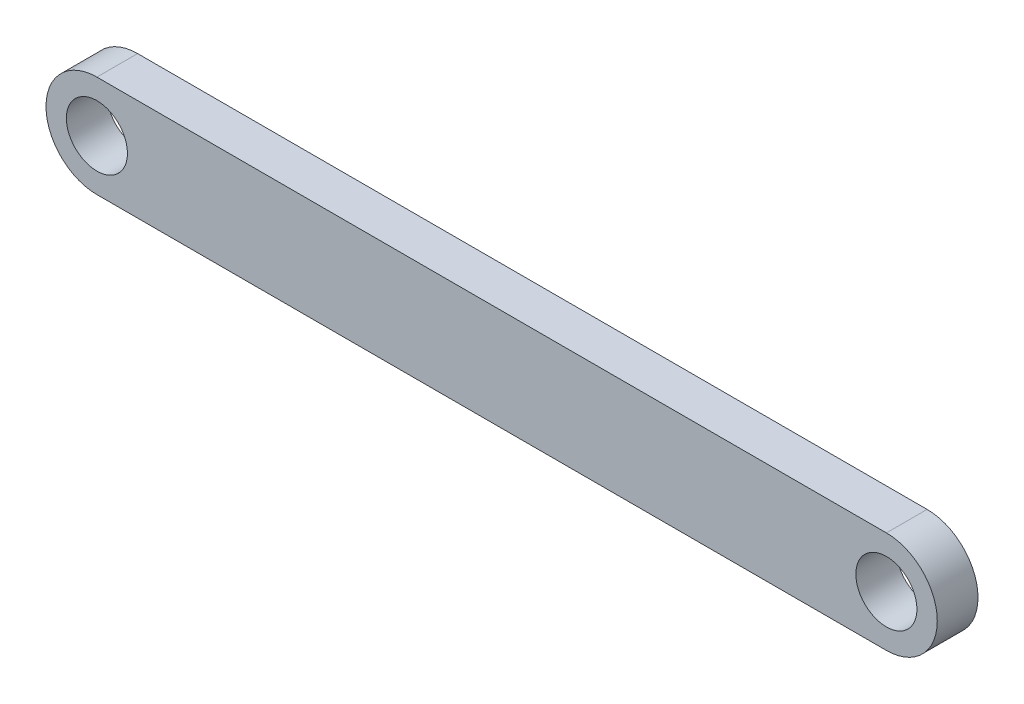
from build123d import *

# Parameters (mm, degrees)
SKETCH1_R           = 1.5
BOSS_EXTRUDE1_DEPTH = 2


with BuildPart() as part:
    # Sketch1 → Boss-Extrude1 (new body)
    with BuildSketch(Plane.XY):
        with BuildLine():
            Line((0.087077843, 2.502267711), (38.867077843, 2.502267711))
            ThreePointArc((38.867077843, 2.502267711), (41.367077843, 0.002267711), (38.867077843, -2.497732289))
            Line((38.867077843, -2.497732289), (0.087077843, -2.497732289))
            ThreePointArc((0.087077843, -2.497732289), (-2.412922157, 0.002267711), (0.087077843, 2.502267711))
        make_face()
        with Locations((0.087077843, 0.002267711)):
            Circle(SKETCH1_R, mode=Mode.SUBTRACT)
        with Locations((38.867077843, 0.002267711)):
            Circle(SKETCH1_R, mode=Mode.SUBTRACT)
    extrude(amount=BOSS_EXTRUDE1_DEPTH)


solid = part.part
